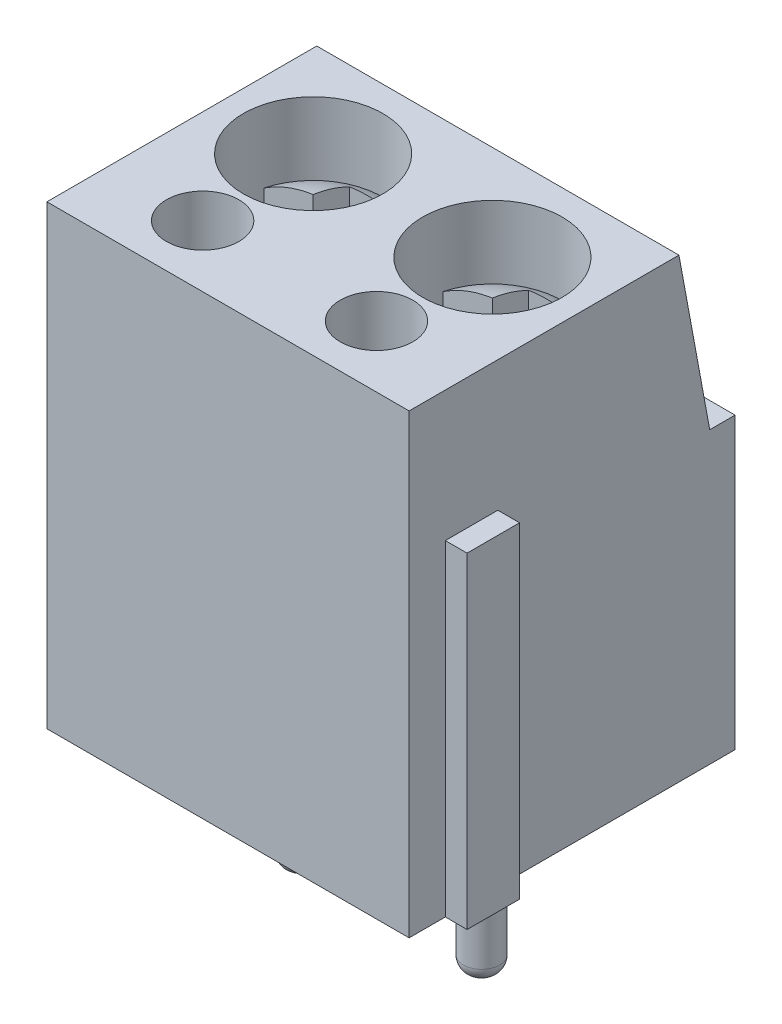
from build123d import *

# Parameters (mm, degrees)
BOSS_EXTRUDE1_DEPTH          = 10
SKETCH2_W                    = 4
SKETCH2_H                    = 6
CUT_EXTRUDE1_DEPTH           = 2
SKETCH3_W                    = 1
SKETCH3_H                    = 1
CUT_EXTRUDE2_DEPTH           = 5
SKETCH4_R                    = 1.5
CUT_EXTRUDE3_DEPTH           = 5
BOSS_EXTRUDE2_DEPTH          = 0.1
SKETCH7_R                    = 0.499
BOSS_EXTRUDE5_DEPTH          = 5.3
SKETCH8_W                    = 1.3
SKETCH8_H                    = 9
CUT_EXTRUDE4_DEPTH           = 0.6
SKETCH9_W                    = 1.45
SKETCH9_H                    = 9
BOSS_EXTRUDE6_DEPTH          = 0.6
SKETCH10_R                   = 1.925
SKETCH10_R_2                 = 1
CUT_EXTRUDE5_DEPTH           = 2
SKETCH11_W                   = 2
SKETCH11_H                   = 0.1
BOSS_EXTRUDE7_DEPTH          = 3
FILLET1_R                    = 0.1
FILLET2_R                    = 0.4
SKETCH15_W                   = 1
SKETCH15_H                   = 1
CUT_EXTRUDE6_DEPTH           = 3
SKETCH16_R                   = 1
CUT_EXTRUDE7_DEPTH           = 3
CUT_EXTRUDE8_DEPTH           = 1
CUT_EXTRUDE8_DRAFT           = -20
CUT_EXTRUDE8_PROFILE_2_DEPTH = 1
CUT_EXTRUDE8_PROFILE_2_DRAFT = -20


with BuildPart() as part:
    # Sketch1 → Boss-Extrude1 (new body)
    with BuildSketch(Plane(origin=(0, 0, 0), x_dir=(0, 0, -1), z_dir=(1, 0, 0))):
        Polygon((0, 0), (0, 12.6), (7.45, 12.6), (8.3, 8), (9, 8), (9, 0), align=None)
    extrude(amount=BOSS_EXTRUDE1_DEPTH)

    # Sketch2 → Cut-Extrude1 (cut)
    with BuildSketch(Plane(origin=(0, 0, -9), x_dir=(-1, 0, 0), z_dir=(0, 0, -1))):
        with Locations((-7.5, 4)):
            Rectangle(SKETCH2_W, SKETCH2_H)
        with Locations((-2.5, 4)):
            Rectangle(SKETCH2_W, SKETCH2_H)
    extrude(amount=-CUT_EXTRUDE1_DEPTH, mode=Mode.SUBTRACT)

    # Sketch3 → Cut-Extrude2 (cut)
    with BuildSketch(Plane(origin=(0, 0, -9), x_dir=(-1, 0, 0), z_dir=(0, 0, -1))):
        with Locations((-7.5, 0.5)):
            Rectangle(SKETCH3_W, SKETCH3_H)
        with Locations((-2.5, 0.5)):
            Rectangle(SKETCH3_W, SKETCH3_H)
    extrude(amount=-CUT_EXTRUDE2_DEPTH, mode=Mode.SUBTRACT)

    # Sketch4 → Cut-Extrude3 (cut)
    with BuildSketch(Plane(origin=(0, 0, -7), x_dir=(-1, 0, 0), z_dir=(0, 0, -1))):
        with Locations(Location((-7.5, 3.5, 0), (0, 0, 90))):
            Circle(SKETCH4_R)
        with Locations(Location((-2.5, 3.5, 0), (0, 0, 90))):
            Circle(SKETCH4_R)
    extrude(amount=-CUT_EXTRUDE3_DEPTH, mode=Mode.SUBTRACT)

    # Sketch6 → Boss-Extrude2 (add)
    with BuildSketch(Plane(origin=(0, 0, -7), x_dir=(-1, 0, 0), z_dir=(0, 0, -1))):
        Polygon((-9.5, 7), (-8.5, 4), (-6.5, 4), (-5.5, 7), align=None)
        Polygon((-4.5, 7), (-0.5, 7), (-1.5, 4), (-3.5, 4), align=None)
    extrude(amount=BOSS_EXTRUDE2_DEPTH)

    # Sketch7 → Boss-Extrude5 (add)
    with BuildSketch(Plane.XZ.offset(-1)):
        with Locations(Location((2.5, -4.5, 0), (0, 0, 90))):
            Circle(SKETCH7_R)
        with Locations(Location((7.5, -4.5, 0), (0, 0, 90))):
            Circle(SKETCH7_R)
    extrude(amount=BOSS_EXTRUDE5_DEPTH)

    # Sketch8 → Cut-Extrude4 (cut)
    with BuildSketch(Plane.ZY):
        with Locations((-1.65, 4.5)):
            Rectangle(SKETCH8_W, SKETCH8_H)
    extrude(amount=-CUT_EXTRUDE4_DEPTH, mode=Mode.SUBTRACT)

    # Sketch9 → Boss-Extrude6 (add)
    with BuildSketch(Plane(origin=(10, 0, 0), x_dir=(0, 0, -1), z_dir=(1, 0, 0))):
        with Locations((1.725, 4.5)):
            Rectangle(SKETCH9_W, SKETCH9_H)
    extrude(amount=BOSS_EXTRUDE6_DEPTH)

    # Sketch10 → Cut-Extrude5 (cut)
    with BuildSketch(Plane(origin=(0, 12.6, 0), x_dir=(1, 0, 0), z_dir=(0, 1, 0))):
        with Locations(Location((2.525, 4.825, 0), (0, 0, 270))):
            Circle(SKETCH10_R)
        with Locations(Location((7.4, 1.7, 0), (0, 0, 90))):
            Circle(SKETCH10_R_2)
        with Locations(Location((2.6, 1.7, 0), (0, 0, 270))):
            Circle(SKETCH10_R_2)
        with Locations(Location((7.475, 4.825, 0), (0, 0, 90))):
            Circle(SKETCH10_R)
    extrude(amount=-CUT_EXTRUDE5_DEPTH, mode=Mode.SUBTRACT)

    # Sketch11 → Boss-Extrude7 (add)
    with BuildSketch(Plane(origin=(0, 0, -7.1), x_dir=(-1, 0, 0), z_dir=(0, 0, -1))):
        with Locations((-7.5, 3.95)):
            Rectangle(SKETCH11_W, SKETCH11_H)
        with Locations((-2.5, 3.95)):
            Rectangle(SKETCH11_W, SKETCH11_H)
    extrude(amount=-BOSS_EXTRUDE7_DEPTH)

    # Fillet1
    fillet1_edges = [part.edges().sort_by_distance(p)[0] for p in [
        (2.5, 3.9, -7.1),
        (7.5, 3.9, -7.1),
    ]]
    fillet(fillet1_edges, radius=FILLET1_R)

    # Fillet2
    fillet2_edges = [part.edges().sort_by_distance(p)[0] for p in [
        (2.5, -4.3, -4.999),
        (7.5, -4.3, -4.999),
    ]]
    fillet(fillet2_edges, radius=FILLET2_R)

    # Sketch13 → Revolve1 (revolve)
    with BuildSketch(Plane.XY.offset(-4.825)):
        with BuildLine():
            Line((7.475, 11.197885), (7.475, 10.6))
            Line((7.475, 10.6), (9.4, 10.6))
            ThreePointArc((9.4, 10.6), (8.482856, 11.044973), (7.475, 11.197885))
        make_face()
    revolve1 = revolve(axis=Axis((7.475, 10.6, -4.825), (0, 1, 0)))

    # Sketch15 → Cut-Extrude6 (cut)
    with BuildSketch(Plane(origin=(0, 12.6, 0), x_dir=(1, 0, 0), z_dir=(0, 1, 0))):
        with BuildLine():
            Line((9.333931, 5.325), (7.975, 5.325))
            Line((7.975, 5.325), (7.975, 4.325))
            Line((7.975, 4.325), (9.333931, 4.325))
            ThreePointArc((9.333931, 4.325), (9.383411, 4.572827), (9.4, 4.825))
            ThreePointArc((9.4, 4.825), (9.383411, 5.077173), (9.333931, 5.325))
        make_face()
        with Locations((7.475, 4.825)):
            Rectangle(SKETCH15_W, SKETCH15_H)
        with Locations((7.475, 5.825)):
            Rectangle(SKETCH15_W, SKETCH15_H)
        with BuildLine():
            Line((6.975, 4.325), (6.975, 5.325))
            Line((6.975, 5.325), (5.616069, 5.325))
            ThreePointArc((5.616069, 5.325), (5.55, 4.825), (5.616069, 4.325))
            Line((5.616069, 4.325), (6.975, 4.325))
        make_face()
        with Locations((7.475, 3.825)):
            Rectangle(SKETCH15_W, SKETCH15_H)
    cut_extrude6 = extrude(amount=-CUT_EXTRUDE6_DEPTH, mode=Mode.SUBTRACT)

    # Mirror1: Revolve1, Cut-Extrude6 across plane
    add(revolve1.mirror(Plane(origin=(5, 0, 0), x_dir=(0, 0, 1), z_dir=(1, 0, 0))))
    add(cut_extrude6.mirror(Plane(origin=(5, 0, 0), x_dir=(0, 0, 1), z_dir=(1, 0, 0))), mode=Mode.SUBTRACT)

    # Sketch16 → Cut-Extrude7 (cut)
    with BuildSketch(Plane(origin=(0, 10.6, 0), x_dir=(1, 0, 0), z_dir=(0, 1, 0))):
        with Locations(Location((2.6, 1.7, 0), (0, 0, 270))):
            Circle(SKETCH16_R)
        with Locations(Location((7.4, 1.7, 0), (0, 0, 270))):
            Circle(SKETCH16_R)
    extrude(amount=-CUT_EXTRUDE7_DEPTH, mode=Mode.SUBTRACT)


with BuildPart() as cut_extrude8_tool:
    # Sketch17 → Cut-Extrude8 (with draft: the straight prism first)
    with BuildSketch(Plane(origin=(0, 9.6, 0), x_dir=(1, 0, 0), z_dir=(0, 1, 0))):
        with BuildLine():
            Line((2.025, 5.325), (0.666069, 5.325))
            ThreePointArc((0.666069, 5.325), (0.6, 4.825), (0.666069, 4.325))
            Line((0.666069, 4.325), (2.025, 4.325))
            Line((2.025, 4.325), (2.025, 3.325))
            Line((2.025, 3.325), (3.025, 3.325))
            Line((3.025, 3.325), (3.025, 4.325))
            Line((3.025, 4.325), (4.383931, 4.325))
            ThreePointArc((4.383931, 4.325), (4.45, 4.825), (4.383931, 5.325))
            Line((4.383931, 5.325), (3.025, 5.325))
            Line((3.025, 5.325), (3.025, 6.325))
            Line((3.025, 6.325), (2.025, 6.325))
            Line((2.025, 6.325), (2.025, 5.325))
        make_face()
    extrude(amount=-CUT_EXTRUDE8_DEPTH)
    # Cut-Extrude8: the draft: its side faces are tilted about the plane it starts from
    cut_extrude8_sides = [cut_extrude8_tool.faces().sort_by_distance(p)[0] for p in [
        (1.345534, 9.1, -5.325),
        (0.6, 9.1, -4.825),
        (1.345534, 9.1, -4.325),
        (2.025, 9.1, -3.825),
        (2.525, 9.1, -3.325),
        (3.025, 9.1, -3.825),
        (3.704466, 9.1, -4.325),
        (4.45, 9.1, -4.825),
        (3.704466, 9.1, -5.325),
        (3.025, 9.1, -5.825),
        (2.525, 9.1, -6.325),
        (2.025, 9.1, -5.825),
    ]]
    draft(cut_extrude8_sides, Plane(origin=(0, 9.6, 0), x_dir=(1, 0, 0), z_dir=(0, 1, 0)), CUT_EXTRUDE8_DRAFT)


with BuildPart() as part_1:
    add(part.part)

    # Cut-Extrude8: cut by cut_extrude8_tool
    add(cut_extrude8_tool.part, mode=Mode.SUBTRACT)


with BuildPart() as cut_extrude8_profile_2_tool:
    # Sketch17 → Cut-Extrude8 profile 2 (with draft: the straight prism first)
    with BuildSketch(Plane(origin=(0, 9.6, 0), x_dir=(1, 0, 0), z_dir=(0, 1, 0))):
        with BuildLine():
            Line((9.333931, 5.325), (7.975, 5.325))
            Line((7.975, 5.325), (7.975, 6.325))
            Line((7.975, 6.325), (6.975, 6.325))
            Line((6.975, 6.325), (6.975, 5.325))
            Line((6.975, 5.325), (5.616069, 5.325))
            ThreePointArc((5.616069, 5.325), (5.55, 4.825), (5.616069, 4.325))
            Line((5.616069, 4.325), (6.975, 4.325))
            Line((6.975, 4.325), (6.975, 3.325))
            Line((6.975, 3.325), (7.975, 3.325))
            Line((7.975, 3.325), (7.975, 4.325))
            Line((7.975, 4.325), (9.333931, 4.325))
            ThreePointArc((9.333931, 4.325), (9.4, 4.825), (9.333931, 5.325))
        make_face()
    extrude(amount=-CUT_EXTRUDE8_PROFILE_2_DEPTH)
    # Cut-Extrude8 profile 2: the draft: its side faces are tilted about the plane it starts from
    cut_extrude8_profile_2_sides = [cut_extrude8_profile_2_tool.faces().sort_by_distance(p)[0] for p in [
        (8.654466, 9.1, -5.325),
        (7.975, 9.1, -5.825),
        (7.475, 9.1, -6.325),
        (6.975, 9.1, -5.825),
        (6.295534, 9.1, -5.325),
        (5.55, 9.1, -4.825),
        (6.295534, 9.1, -4.325),
        (6.975, 9.1, -3.825),
        (7.475, 9.1, -3.325),
        (7.975, 9.1, -3.825),
        (8.654466, 9.1, -4.325),
        (9.4, 9.1, -4.825),
    ]]
    draft(cut_extrude8_profile_2_sides, Plane(origin=(0, 9.6, 0), x_dir=(1, 0, 0), z_dir=(0, 1, 0)), CUT_EXTRUDE8_PROFILE_2_DRAFT)


with BuildPart() as part_2:
    add(part_1.part)

    # Cut-Extrude8 profile 2: cut by cut_extrude8_profile_2_tool
    add(cut_extrude8_profile_2_tool.part, mode=Mode.SUBTRACT)


solid = part_2.part
